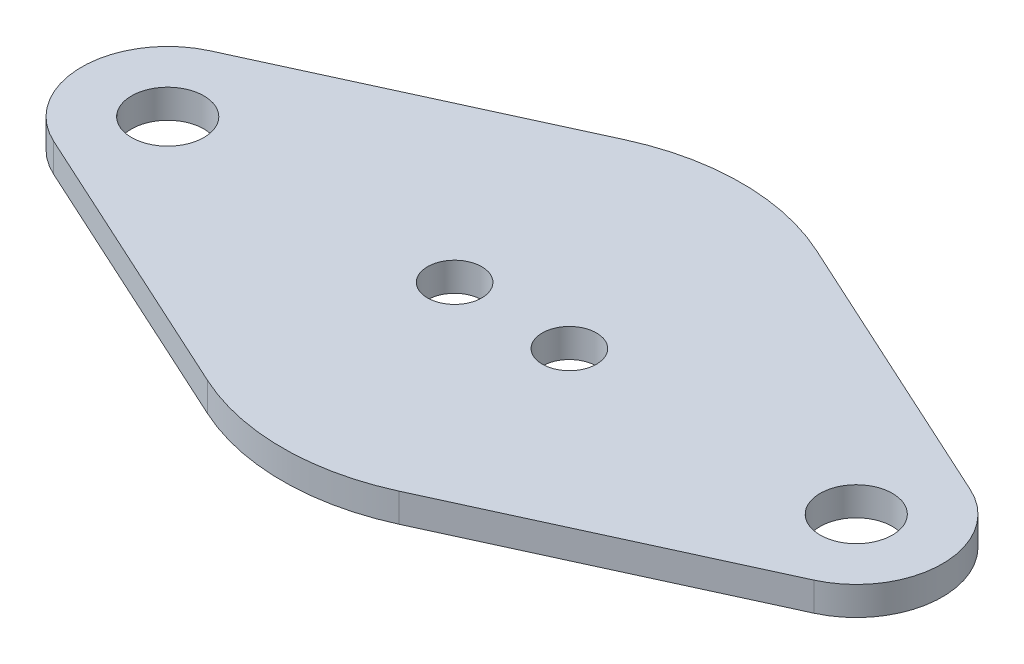
from build123d import *

# Parameters (mm, degrees)
SKETCH1_R           = 4
SKETCH1_R_2         = 3
BOSS_EXTRUDE1_DEPTH = 3.175


with BuildPart() as part:
    # Sketch1 → Boss-Extrude1 (new body)
    with BuildSketch(Plane(origin=(0, 0, 0), x_dir=(1, 0, 0), z_dir=(0, 1, 0))):
        with BuildLine():
            Line((-42.06875, 8.658790241), (-10.583333333, 23.090107309))
            ThreePointArc((-10.583333333, 23.090107309), (0, 25.4), (10.583333333, 23.090107309))
            Line((10.583333333, 23.090107309), (42.06875, 8.658790241))
            ThreePointArc((42.06875, 8.658790241), (47.625, 0), (42.06875, -8.658790241))
            Line((42.06875, -8.658790241), (10.583333333, -23.090107309))
            ThreePointArc((10.583333333, -23.090107309), (0, -25.4), (-10.583333333, -23.090107309))
            Line((-10.583333333, -23.090107309), (-42.06875, -8.658790241))
            ThreePointArc((-42.06875, -8.658790241), (-47.625, 0), (-42.06875, 8.658790241))
        make_face()
        with Locations((-38.1, 0)):
            Circle(SKETCH1_R, mode=Mode.SUBTRACT)
        with Locations((38.1, 0)):
            Circle(SKETCH1_R, mode=Mode.SUBTRACT)
        with Locations((6.35, 0)):
            Circle(SKETCH1_R_2, mode=Mode.SUBTRACT)
        with Locations((-6.35, 0)):
            Circle(SKETCH1_R_2, mode=Mode.SUBTRACT)
    extrude(amount=-BOSS_EXTRUDE1_DEPTH)


solid = part.part
